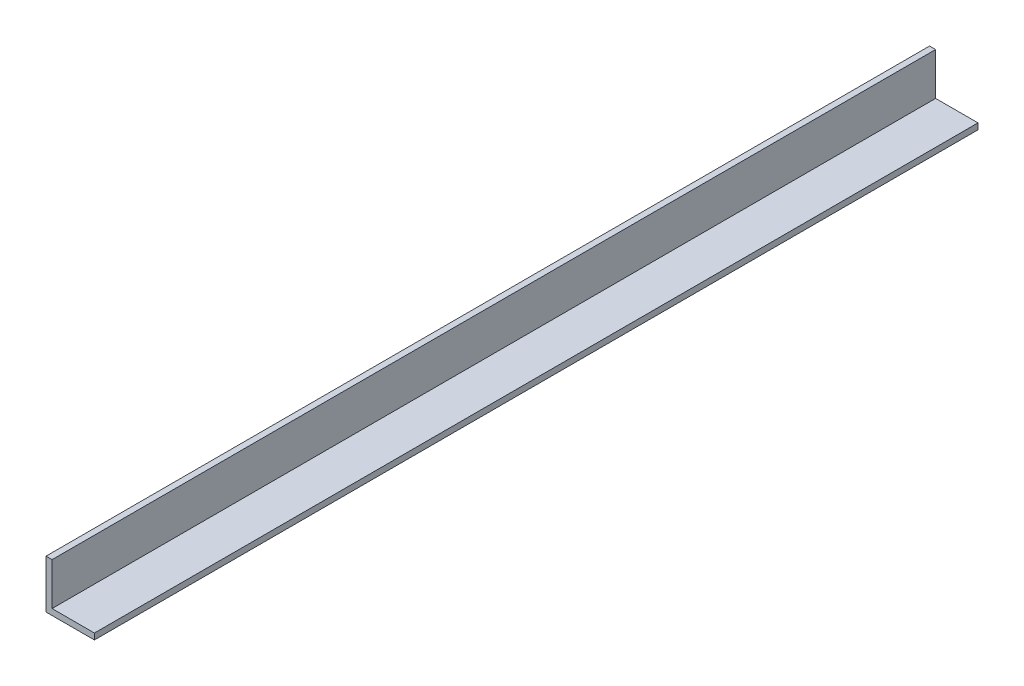
from build123d import *

# Parameters (mm, degrees)
BOSS_EXTRUDE1_DEPTH = 927.1


with BuildPart() as part:
    # Sketch1 → Boss-Extrude1 (new body)
    with BuildSketch(Plane.XY):
        Polygon((0, 0), (0, 50.8), (6.35, 50.8), (6.35, 6.35), (50.8, 6.35), (50.8, 0), align=None)
    extrude(amount=BOSS_EXTRUDE1_DEPTH)


solid = part.part
